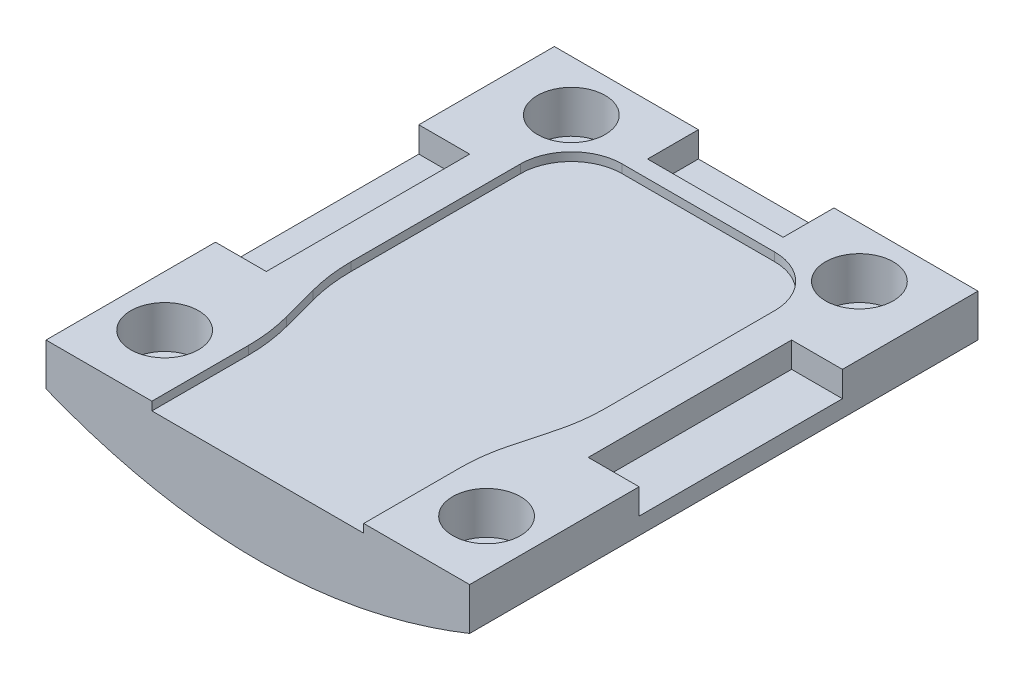
from build123d import *

# Parameters (mm, degrees)
SKETCH1_W           = 25
SKETCH1_H           = 30
BOSS_EXTRUDE1_DEPTH = 2.5
CUT_EXTRUDE1_DEPTH  = 0.5
SKETCH3_R           = 2
CUT_EXTRUDE2_DEPTH  = 3.5
BOSS_EXTRUDE2_DEPTH = 30
SKETCH5_W           = 8
SKETCH5_H           = 3
SKETCH5_W_2         = 3
SKETCH5_H_2         = 12
CUT_EXTRUDE3_DEPTH  = 1.5


with BuildPart() as part:
    # Sketch1 → Boss-Extrude1 (new body)
    with BuildSketch(Plane(origin=(0, 0, 0), x_dir=(1, 0, 0), z_dir=(0, 1, 0))):
        with Locations((12.5, 15)):
            Rectangle(SKETCH1_W, SKETCH1_H)
    extrude(amount=BOSS_EXTRUDE1_DEPTH)

    # Sketch2 → Cut-Extrude1 (cut)
    with BuildSketch(Plane(origin=(0, 2.5, 0), x_dir=(1, 0, 0), z_dir=(0, 1, 0))):
        with BuildLine():
            Line((8, 26), (17, 26))
            ThreePointArc((17, 26), (19.121320344, 25.121320344), (20, 23))
            Line((20, 23), (20, 13))
            ThreePointArc((20, 13), (19.915325472, 11.701415851), (19.662735842, 10.424823102))
            Line((19.662735842, 10.424823102), (19.087264158, 8.265503148))
            ThreePointArc((19.087264158, 8.265503148), (18.834674528, 6.988910399), (18.75, 5.690326251))
            Line((18.75, 5.690326251), (18.75, 0))
            Line((18.75, 0), (6.25, 0))
            Line((6.25, 0), (6.25, 5.690326251))
            ThreePointArc((6.25, 5.690326251), (6.165325472, 6.988910399), (5.912735842, 8.265503148))
            Line((5.912735842, 8.265503148), (5.337264158, 10.424823102))
            ThreePointArc((5.337264158, 10.424823102), (5.084674528, 11.701415851), (5, 13))
            Line((5, 13), (5, 23))
            ThreePointArc((5, 23), (5.878679656, 25.121320344), (8, 26))
        make_face()
    extrude(amount=-CUT_EXTRUDE1_DEPTH, mode=Mode.SUBTRACT)

    # Sketch3 → Cut-Extrude2 (cut)
    with BuildSketch(Plane(origin=(0, 2.5, 0), x_dir=(1, 0, 0), z_dir=(0, 1, 0))):
        with Locations((21, 27)):
            Circle(SKETCH3_R)
        with Locations((4, 27)):
            Circle(SKETCH3_R)
        with Locations((3, 4)):
            Circle(SKETCH3_R)
        with Locations((22, 4)):
            Circle(SKETCH3_R)
    extrude(amount=-CUT_EXTRUDE2_DEPTH, mode=Mode.SUBTRACT)

    # Sketch4 → Boss-Extrude2 (add)
    with BuildSketch(Plane.XY):
        with BuildLine():
            Line((25, 0), (0, 0))
            add(Edge.make_bspline(
                [(25, 0), (12.5, -5), (0, 0)],
                knots=[0, 0, 0, 1, 1, 1], degree=2))
        make_face()
    extrude(amount=-BOSS_EXTRUDE2_DEPTH)

    # Sketch5 → Cut-Extrude3 (cut)
    with BuildSketch(Plane(origin=(0, 2.5, 0), x_dir=(1, 0, 0), z_dir=(0, 1, 0))):
        with Locations((12.5, 28.5)):
            Rectangle(SKETCH5_W, SKETCH5_H)
        with Locations((23.5, 16)):
            Rectangle(SKETCH5_W_2, SKETCH5_H_2)
        with Locations((1.5, 16)):
            Rectangle(SKETCH5_W_2, SKETCH5_H_2)
    extrude(amount=-CUT_EXTRUDE3_DEPTH, mode=Mode.SUBTRACT)


solid = part.part
